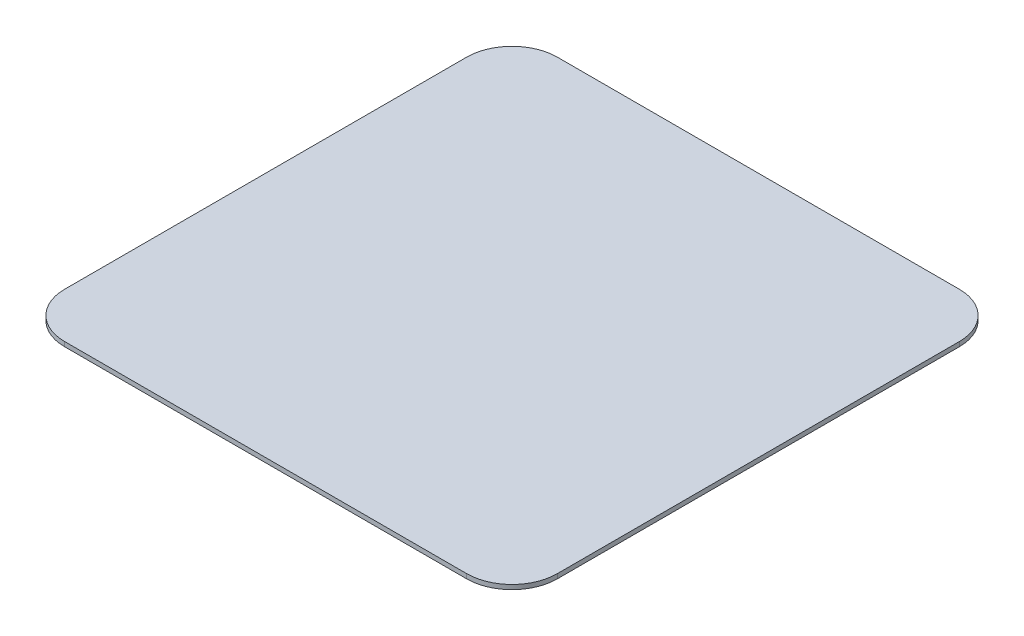
from build123d import *

# Parameters (mm, degrees)
BOSS_EXTRUDE1_DEPTH   = 0.1
BOSS_EXTRUDE2_START   = -0.1
BOSS_EXTRUDE2_DEPTH   = 1
BOSS_EXTRUDE3_DEPTH   = 4
BOSS_EXTRUDE3_2_DEPTH = 4
BOSS_EXTRUDE3_3_DEPTH = 4
BOSS_EXTRUDE3_4_DEPTH = 4


with BuildPart() as part:
    # Sketch2 → Boss-Extrude1 (new body)
    with BuildSketch(Plane(origin=(0, 0, 0), x_dir=(1, 0, 0), z_dir=(0, 1, 0))):
        with BuildLine():
            Line((44.4, 52.9), (-44.4, 52.9))
            ThreePointArc((-44.4, 52.9), (-50.41040764, 50.41040764), (-52.9, 44.4))
            Line((-52.9, 44.4), (-52.9, -44.4))
            ThreePointArc((-52.9, -44.4), (-50.41040764, -50.41040764), (-44.4, -52.9))
            Line((-44.4, -52.9), (44.4, -52.9))
            ThreePointArc((44.4, -52.9), (50.41040764, -50.41040764), (52.9, -44.4))
            Line((52.9, -44.4), (52.9, 44.4))
            ThreePointArc((52.9, 44.4), (50.41040764, 50.41040764), (44.4, 52.9))
        make_face()
        with BuildLine():
            Line((44.4, 51.9), (-44.4, 51.9))
            ThreePointArc((-44.4, 51.9), (-49.703300859, 49.703300859), (-51.9, 44.4))
            Line((-51.9, 44.4), (-51.9, -44.4))
            ThreePointArc((-51.9, -44.4), (-49.703300859, -49.703300859), (-44.4, -51.9))
            Line((-44.4, -51.9), (44.4, -51.9))
            ThreePointArc((44.4, -51.9), (49.703300859, -49.703300859), (51.9, -44.4))
            Line((51.9, -44.4), (51.9, 44.4))
            ThreePointArc((51.9, 44.4), (49.703300859, 49.703300859), (44.4, 51.9))
        make_face(mode=Mode.SUBTRACT)
    extrude(amount=-BOSS_EXTRUDE1_DEPTH)

    # Sketch1 → Boss-Extrude2 (add)
    with BuildSketch(Plane(origin=(0, 0, 0), x_dir=(1, 0, 0), z_dir=(0, 1, 0)).offset(BOSS_EXTRUDE2_START)):
        with BuildLine():
            Line((54.4, -44.4), (54.4, 44.4))
            ThreePointArc((54.4, 44.4), (51.471067812, 51.471067812), (44.4, 54.4))
            Line((44.4, 54.4), (-44.4, 54.4))
            ThreePointArc((-44.4, 54.4), (-51.471067812, 51.471067812), (-54.4, 44.4))
            Line((-54.4, 44.4), (-54.4, -44.4))
            ThreePointArc((-54.4, -44.4), (-51.471067812, -51.471067812), (-44.4, -54.4))
            Line((-44.4, -54.4), (44.4, -54.4))
            ThreePointArc((44.4, -54.4), (51.471067812, -51.471067812), (54.4, -44.4))
        make_face()
        with BuildLine():
            ThreePointArc((-44.4, 53.4), (-50.763961031, 50.763961031), (-53.4, 44.4))
            Line((-53.4, 44.4), (-53.4, -44.4))
            ThreePointArc((-53.4, -44.4), (-50.763961031, -50.763961031), (-44.4, -53.4))
            Line((-44.4, -53.4), (44.4, -53.4))
            ThreePointArc((44.4, -53.4), (50.763961031, -50.763961031), (53.4, -44.4))
            Line((53.4, -44.4), (53.4, 44.4))
            ThreePointArc((53.4, 44.4), (50.763961031, 50.763961031), (44.4, 53.4))
            Line((44.4, 53.4), (-44.4, 53.4))
        make_face(mode=Mode.SUBTRACT)
        with BuildLine():
            Line((-44.4, 53.4), (44.4, 53.4))
            ThreePointArc((44.4, 53.4), (50.763961031, 50.763961031), (53.4, 44.4))
            Line((53.4, 44.4), (53.4, -44.4))
            ThreePointArc((53.4, -44.4), (50.763961031, -50.763961031), (44.4, -53.4))
            Line((44.4, -53.4), (-44.4, -53.4))
            ThreePointArc((-44.4, -53.4), (-50.763961031, -50.763961031), (-53.4, -44.4))
            Line((-53.4, -44.4), (-53.4, 44.4))
            ThreePointArc((-53.4, 44.4), (-50.763961031, 50.763961031), (-44.4, 53.4))
        make_face()
    extrude(amount=BOSS_EXTRUDE2_DEPTH)


with BuildPart() as body_2:
    # Sketch3 → Boss-Extrude3 (new body)
    with BuildSketch(Plane.XZ.offset(0.1)):
        Polygon((-41.140539781, 40.026118716), (-37.997071749, 34.468775471), (-31.612537306, 34.41242702), (-28.371470895, 39.913421814), (-31.514938926, 45.470765058), (-37.899473369, 45.527113509), align=None)
    extrude(amount=BOSS_EXTRUDE3_DEPTH)


with BuildPart() as body_3:
    # Sketch3 → Boss-Extrude3 2 (new body)
    with BuildSketch(Plane.XZ.offset(0.1)):
        Polygon((23.419460219, 40.026118716), (26.56292825, 34.468775471), (32.947462693, 34.41242702), (36.188529105, 39.913421814), (33.045061073, 45.470765058), (26.66052663, 45.527113509), align=None)
    extrude(amount=BOSS_EXTRUDE3_2_DEPTH)


with BuildPart() as body_4:
    # Sketch3 → Boss-Extrude3 3 (new body)
    with BuildSketch(Plane.XZ.offset(0.1)):
        Polygon((34.321988768, -39.663881284), (37.4654568, -45.221224529), (43.849991243, -45.27757298), (47.091057654, -39.776578186), (43.947589623, -34.219234942), (37.56305518, -34.162886491), align=None)
    extrude(amount=BOSS_EXTRUDE3_3_DEPTH)


with BuildPart() as body_5:
    # Sketch3 → Boss-Extrude3 4 (new body)
    with BuildSketch(Plane.XZ.offset(0.1)):
        Polygon((-41.140539781, -33.533881284), (-37.997071749, -39.091224529), (-31.612537306, -39.14757298), (-28.371470895, -33.646578186), (-31.514938926, -28.089234942), (-37.899473369, -28.032886491), align=None)
    extrude(amount=BOSS_EXTRUDE3_4_DEPTH)


solid = Compound([part.part, body_2.part, body_3.part, body_4.part, body_5.part])
